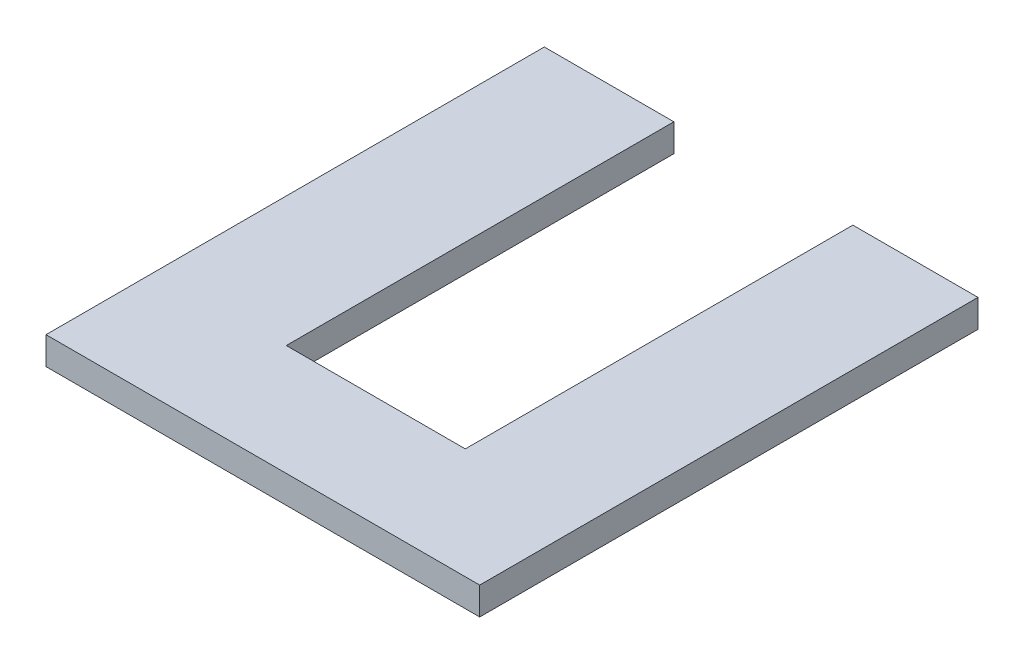
from build123d import *

# Parameters (mm, degrees)
ESBO_O1_W                = 2350
ESBO_O1_H                = 150
RESSALTO_EXTRUS_O1_DEPTH = 2700
ESBO_O2_W                = 970
ESBO_O2_H                = 2100
CORTE_EXTRUS_O1_DEPTH    = 151


with BuildPart() as part:
    # Esboço1 → Ressalto-extrusão1 (new body)
    with BuildSketch(Plane.XY):
        with Locations((1175, 75)):
            Rectangle(ESBO_O1_W, ESBO_O1_H)
    extrude(amount=RESSALTO_EXTRUS_O1_DEPTH)

    # Esboço2 → Corte-extrusão1 (cut, through all)
    with BuildSketch(Plane(origin=(0, 150, 0), x_dir=(1, 0, 0), z_dir=(0, 1, 0))):
        with Locations((1187, -1050)):
            Rectangle(ESBO_O2_W, ESBO_O2_H)
    extrude(amount=-CORTE_EXTRUS_O1_DEPTH, mode=Mode.SUBTRACT)


solid = part.part
